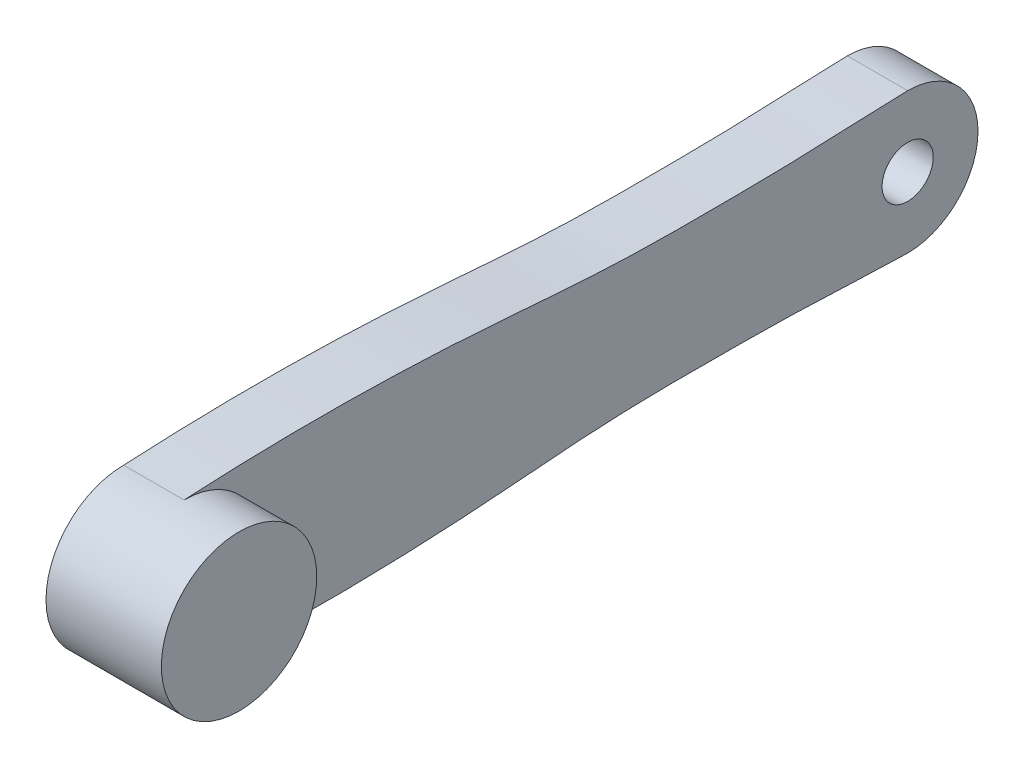
from build123d import *

# Parameters (mm, degrees)
SKETCH1_R                    = 18.225
BOSS_EXTRUDE1_DEPTH          = 27.06
CUT_EXTRUDE1_DEPTH           = 5.8
BOSS_EXTRUDE2_DEPTH          = 14.15
TAP_DRILL_FOR_M14X2_0_TAP1_D = 12
SKETCH8_R                    = 10
CUT_EXTRUDE2_DEPTH           = 2.5


with BuildPart() as part:
    # Sketch1 → Boss-Extrude1 (new body)
    with BuildSketch(Plane(origin=(0, 0, 0), x_dir=(0, 0, -1), z_dir=(1, 0, 0))):
        Circle(SKETCH1_R)
    extrude(amount=BOSS_EXTRUDE1_DEPTH)

    # Sketch2 → Cut-Extrude1 (cut)
    with BuildSketch(Plane.ZY):
        Polygon((4.618802154, 0), (2.309401077, 4), (-2.309401077, 4), (-4.618802154, 0), (-2.309401077, -4), (2.309401077, -4), align=None)
    extrude(amount=-CUT_EXTRUDE1_DEPTH, mode=Mode.SUBTRACT)

    # Sketch3 → Boss-Extrude2 (add)
    with BuildSketch(Plane.ZY):
        with BuildLine():
            ThreePointArc((-169.749999999, 16.5), (-186.25, 1e-09), (-169.75, -16.5))
            add(Edge.make_bspline(
                [(-169.75, -16.5), (-159.749007012, -16.27034763), (-146.423041336, -15.435466348), (-123.084465671, -15.240795583), (-99.700937004, -15.146825519), (-56.582760429, -19.333044357), (-23.234269391, -19.487462019), (0, -18.225)],
                knots=[0, 0, 0, 0, 0.176707611, 0.235576803, 0.412182603, 0.589218848, 1, 1, 1, 1], degree=3))
            ThreePointArc((0, -18.225), (-18.225, -1e-09), (-1e-09, 18.225))
            add(Edge.make_bspline(
                [(-169.749999999, 16.5), (-159.749007011, 16.27034763), (-146.423041336, 15.435466348), (-123.084465671, 15.240795583), (-99.700937004, 15.146825519), (-56.582760429, 19.333044357), (-23.234269392, 19.487462019), (-1e-09, 18.225)],
                knots=[0, 0, 0, 0, 0.176707611, 0.235576803, 0.412182603, 0.589218848, 1, 1, 1, 1], degree=3))
        make_face()
    extrude(amount=-BOSS_EXTRUDE2_DEPTH)

    # Tap Drill for M14x2.0 Tap1 (through all)
    with Locations(Plane.ZY):
        with Locations((-169.75, 0)):
            Hole(TAP_DRILL_FOR_M14X2_0_TAP1_D / 2)

    # Sketch8 → Cut-Extrude2 (cut)
    with BuildSketch(Plane.ZY):
        with Locations((-169.75, 0)):
            Circle(SKETCH8_R)
    extrude(amount=-CUT_EXTRUDE2_DEPTH, mode=Mode.SUBTRACT)


solid = part.part
